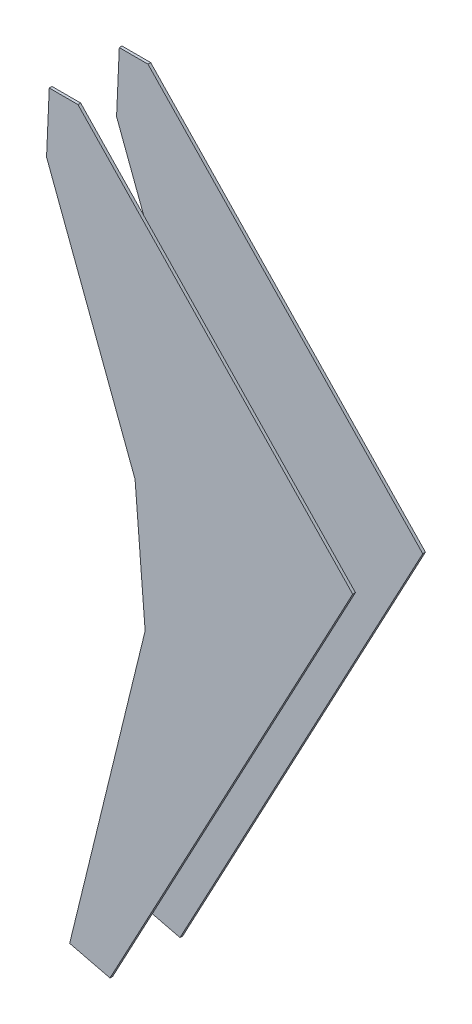
from build123d import *

# Parameters (mm, degrees)
BOSS_EXTRUDE1_START = 65
BOSS_EXTRUDE1_DEPTH = 5.25
BOSS_EXTRUDE2_START = -65
BOSS_EXTRUDE2_DEPTH = 5.25


with BuildPart() as part:
    # Sketch1 → Boss-Extrude1 (new body)
    with BuildSketch(Plane.XY.offset(BOSS_EXTRUDE1_START)):
        Polygon((295.675074254, 161.480188615), (-235.091721205, 715.062577473), (-290.413622869, 715.062577473), (-295.675074254, 596.921443574), (-124.723344844, 143.447345429), (-105.228202032, -100.364094919), (-251.02667789, -696.013410022), (-173.202657588, -715.062577473), align=None)
    extrude(amount=BOSS_EXTRUDE1_DEPTH)


with BuildPart() as body_2:
    # Sketch1_2 → Boss-Extrude2 (new body)
    with BuildSketch(Plane.XY.offset(BOSS_EXTRUDE2_START)):
        Polygon((295.675074254, 161.480188615), (-235.091721205, 715.062577473), (-290.413622869, 715.062577473), (-295.675074254, 596.921443574), (-124.723344844, 143.447345429), (-105.228202032, -100.364094919), (-251.02667789, -696.013410022), (-173.202657588, -715.062577473), align=None)
    extrude(amount=-BOSS_EXTRUDE2_DEPTH)


solid = Compound([part.part, body_2.part])
